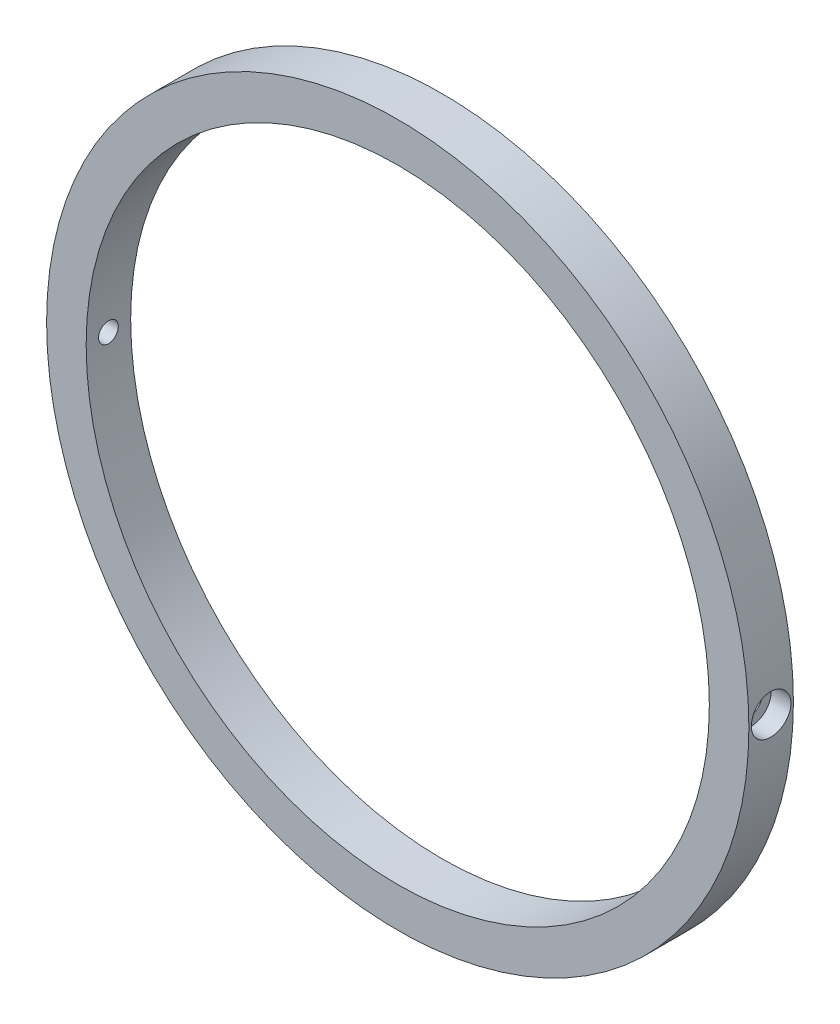
from build123d import *

# Parameters (mm, degrees)
SKETCH1_R           = 56.35625
SKETCH1_R_2         = 50.00625
BOSS_EXTRUDE1_DEPTH = 3.571875
HOLE1_D             = 3.175
HOLE1_DEPTH         = 12.7
HOLE1_CBORE_D       = 6.35
HOLE1_CBORE_DEPTH   = 3.175


with BuildPart() as part:
    # Sketch1 → Boss-Extrude1 (new body, symmetric)
    with BuildSketch(Plane.XY):
        Circle(SKETCH1_R)
        Circle(SKETCH1_R_2, mode=Mode.SUBTRACT)
    extrude(amount=BOSS_EXTRUDE1_DEPTH, both=True)

    # Hole1
    with Locations(Plane.YZ.offset(56.35625)):
        with Locations((0, 0)):
            hole1 = CounterBoreHole(HOLE1_D / 2, HOLE1_CBORE_D / 2, HOLE1_CBORE_DEPTH, depth=HOLE1_DEPTH)

    # Mirror1: Hole1 across plane
    add(hole1.mirror(Plane(origin=(0, 0, 0), x_dir=(0, 0, 1), z_dir=(1, 0, 0))), mode=Mode.SUBTRACT)


solid = part.part
